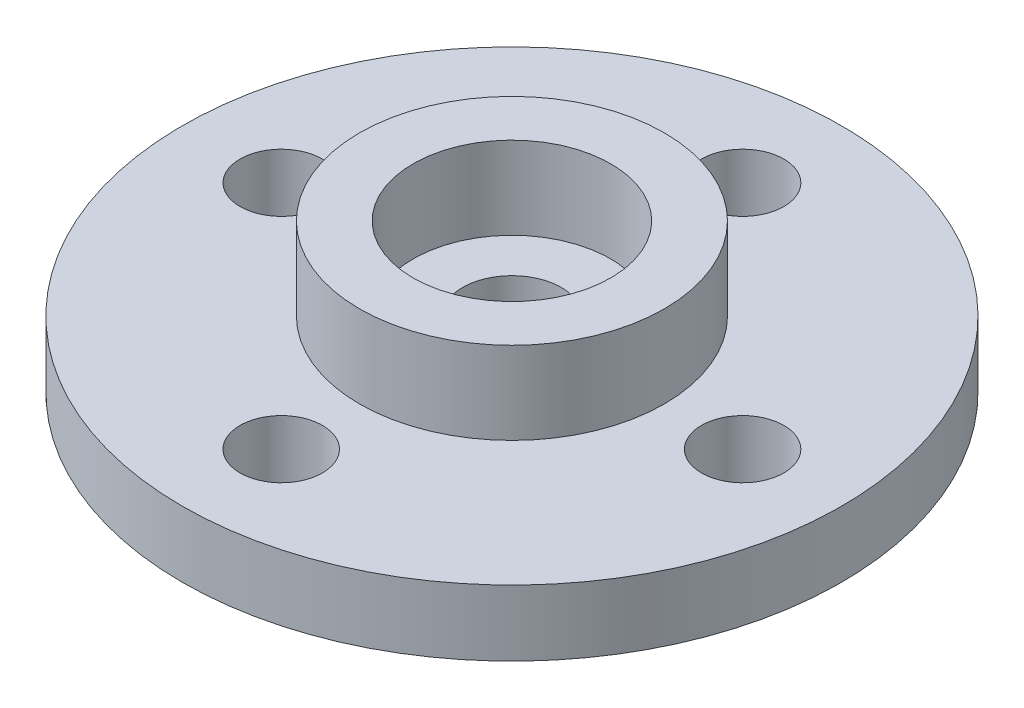
from build123d import *

# Parameters (mm, degrees)
SKETCH1_R           = 10
SKETCH1_R_2         = 1.25
SKETCH1_R_3         = 1.5
BOSS_EXTRUDE1_DEPTH = 2
SKETCH2_R           = 4.625
SKETCH2_R_2         = 3
BOSS_EXTRUDE2_DEPTH = 2.5


with BuildPart() as part:
    # Sketch1 → Boss-Extrude1 (new body)
    with BuildSketch(Plane(origin=(0, 0, 0), x_dir=(1, 0, 0), z_dir=(0, 1, 0))):
        Circle(SKETCH1_R)
        with Locations((0, 7)):
            Circle(SKETCH1_R_2, mode=Mode.SUBTRACT)
        Circle(SKETCH1_R_3, mode=Mode.SUBTRACT)
        with Locations((7, 0)):
            Circle(SKETCH1_R_2, mode=Mode.SUBTRACT)
        with Locations((0, -7)):
            Circle(SKETCH1_R_2, mode=Mode.SUBTRACT)
        with Locations((-7, 0)):
            Circle(SKETCH1_R_2, mode=Mode.SUBTRACT)
    extrude(amount=BOSS_EXTRUDE1_DEPTH)

    # Sketch2 → Boss-Extrude2 (add)
    with BuildSketch(Plane(origin=(0, 2, 0), x_dir=(1, 0, 0), z_dir=(0, 1, 0))):
        Circle(SKETCH2_R)
        Circle(SKETCH2_R_2, mode=Mode.SUBTRACT)
    extrude(amount=BOSS_EXTRUDE2_DEPTH)


solid = part.part
